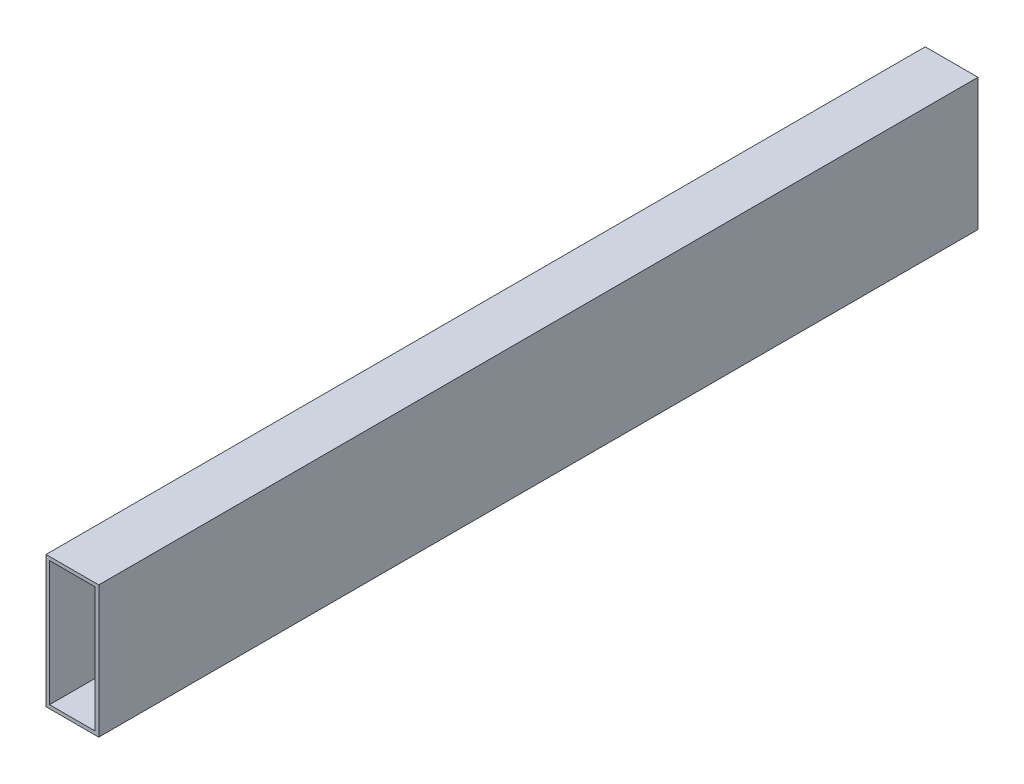
from build123d import *

# Parameters (mm, degrees)
SKETCH1_W   = 60
SKETCH1_H   = 150
SKETCH1_W_2 = 52
SKETCH1_H_2 = 142


with BuildPart() as part:
    # Sweep1: sweep along a curve in space
    with BuildLine() as sweep1_path:
        add(Edge.make_bspline(
            [(0, 0, -500), (0, 0, 500)],
            knots=[0, 0, 1, 1], degree=1))
    # Sketch1 → Sweep1 (sweep)
    with BuildSketch(Plane.XY):
        Rectangle(SKETCH1_W, SKETCH1_H)
        Rectangle(SKETCH1_W_2, SKETCH1_H_2, mode=Mode.SUBTRACT)
    sweep(path=sweep1_path.line)


solid = part.part
